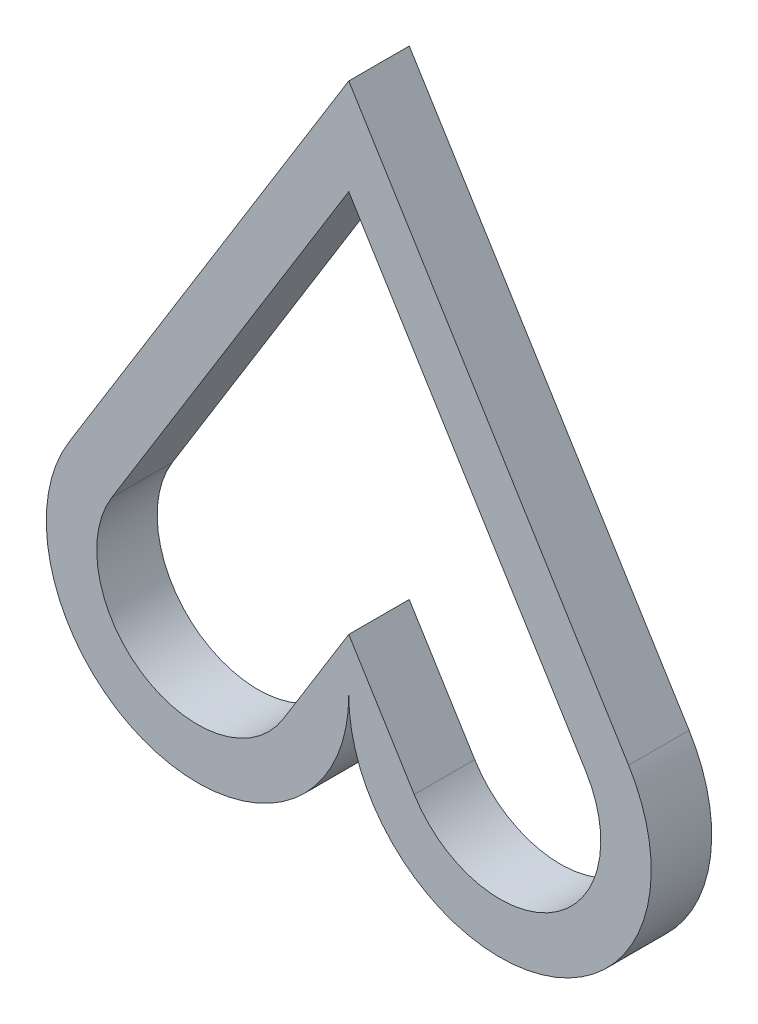
from build123d import *

# Parameters (mm, degrees)
BOSS_EXTRUDE1_DEPTH = 6


with BuildPart() as part:
    # Sketch1 → Boss-Extrude1 (new body)
    with BuildSketch(Plane(origin=(0, 0, 0), x_dir=(1, 0, 0), z_dir=(0, 0, -1))):
        with BuildLine():
            Line((-27.759328596, 44.902453019), (-0.000594147, 0.000961069))
            Line((-0.000594147, 0.000961069), (27.758140303, 44.902453019))
            ThreePointArc((27.758140303, 44.902453019), (19.099343857, 67.218890553), (-0.000594147, 52.790082274))
            ThreePointArc((-0.000594147, 52.790082274), (-19.10053215, 67.218890553), (-27.759328596, 44.902453019))
        make_face()
        with BuildLine():
            Line((23.50522882, 47.531662771), (-0.000594147, 9.509521573))
            Line((-0.000594147, 9.509521573), (-23.506417113, 47.531662771))
            ThreePointArc((-23.506417113, 47.531662771), (-20.25901365, 61.29590524), (-6.49477118, 58.048501777))
            Line((-6.49477118, 58.048501777), (-0.000594147, 47.543763589))
            Line((-0.000594147, 47.543763589), (6.493582887, 58.048501777))
            ThreePointArc((6.493582887, 58.048501777), (20.257825357, 61.29590524), (23.50522882, 47.531662771))
        make_face(mode=Mode.SUBTRACT)
    extrude(amount=BOSS_EXTRUDE1_DEPTH)


solid = part.part
